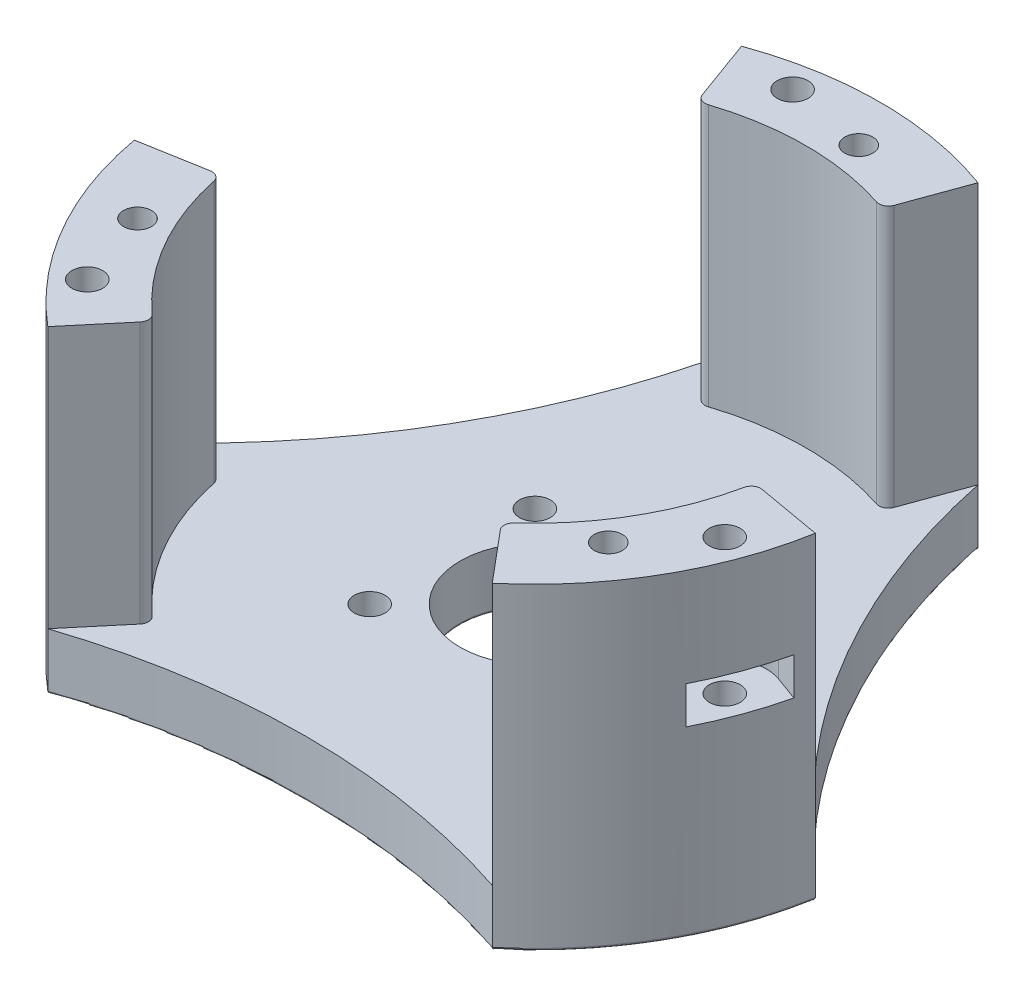
from build123d import *

# Parameters (mm, degrees)
SKETCH1_R           = 37
SKETCH1_R_2         = 1.65
BOSS_EXTRUDE1_DEPTH = 6
SKETCH2_R           = 1.5
BOSS_EXTRUDE2_DEPTH = 28
SKETCH16_R          = 1.5
CUT_EXTRUDE9_DEPTH  = 35
CIRPATTERN1_COUNT   = 3
SKETCH3_R           = 8
CUT_EXTRUDE1_DEPTH  = 10
SKETCH4_R           = 3.5
CUT_EXTRUDE2_DEPTH  = 3
SKETCH5_R           = 75.500139874
CUT_EXTRUDE3_DEPTH  = 7
CIRPATTERN2_COUNT   = 3
FILLET1_R           = 0.25
FILLET2_R           = 1
CUT_EXTRUDE4_START  = -24.5000001
SKETCH9_R           = 1.65
CUT_EXTRUDE4_DEPTH  = 36.0000001
CUT_EXTRUDE5_DEPTH  = 4
CIRPATTERN3_COUNT   = 3


with BuildPart() as part:
    # Sketch1 → Boss-Extrude1 (new body)
    with BuildSketch(Plane(origin=(0, 0, 0), x_dir=(1, 0, 0), z_dir=(0, 1, 0))):
        Circle(SKETCH1_R)
        with Locations((-8.838834765, 8.838834765)):
            Circle(SKETCH1_R_2, mode=Mode.SUBTRACT)
        with Locations((8.838834765, 8.838834765)):
            Circle(SKETCH1_R_2, mode=Mode.SUBTRACT)
        with Locations((8.838834765, -8.838834765)):
            Circle(SKETCH1_R_2, mode=Mode.SUBTRACT)
        with Locations((-8.838834765, -8.838834765)):
            Circle(SKETCH1_R_2, mode=Mode.SUBTRACT)
    extrude(amount=BOSS_EXTRUDE1_DEPTH)

    # Sketch2 → Boss-Extrude2 (add)
    with BuildSketch(Plane(origin=(0, 6, 0), x_dir=(1, 0, 0), z_dir=(0, 1, 0))):
        with BuildLine():
            Line((-12.654745303, 34.768626969), (-9.918584156, 27.251086003))
            ThreePointArc((-9.918584156, 27.251086003), (0, 29), (9.918584156, 27.251086003))
            Line((9.918584156, 27.251086003), (12.654745303, 34.768626969))
            ThreePointArc((12.654745303, 34.768626969), (0, 37), (-12.654745303, 34.768626969))
        make_face()
        with Locations((2.788983768, 31.878230339)):
            Circle(SKETCH2_R, mode=Mode.SUBTRACT)
    boss_extrude2 = extrude(amount=BOSS_EXTRUDE2_DEPTH)

    # Sketch16 → Cut-Extrude9 (cut, through all)
    with BuildSketch(Plane(origin=(0, 34, 0), x_dir=(1, 0, 0), z_dir=(0, 1, 0))):
        with Locations((2.788983768, 31.878230339)):
            Circle(SKETCH16_R)
    cut_extrude9 = extrude(amount=-CUT_EXTRUDE9_DEPTH, mode=Mode.SUBTRACT)

    # CirPattern1: Boss-Extrude2, Cut-Extrude9 ×3 about axis
    cirpattern1_axis = Axis((0, 0, 0), (0, 1, 0))
    for i in range(1, CIRPATTERN1_COUNT):
        add(boss_extrude2.rotate(cirpattern1_axis, i * 360 / CIRPATTERN1_COUNT))
        add(cut_extrude9.rotate(cirpattern1_axis, i * 360 / CIRPATTERN1_COUNT), mode=Mode.SUBTRACT)

    # Sketch3 → Cut-Extrude1 (cut)
    with BuildSketch(Plane(origin=(0, 6, 0), x_dir=(1, 0, 0), z_dir=(0, 1, 0))):
        Circle(SKETCH3_R)
    extrude(amount=-CUT_EXTRUDE1_DEPTH, mode=Mode.SUBTRACT)

    # Sketch4 → Cut-Extrude2 (cut)
    with BuildSketch(Plane.XZ):
        with Locations((8.838834765, 8.838834765)):
            Circle(SKETCH4_R)
        with Locations((8.838834765, -8.838834765)):
            Circle(SKETCH4_R)
        with Locations((-8.838834765, -8.838834765)):
            Circle(SKETCH4_R)
        with Locations((-8.838834765, 8.838834765)):
            Circle(SKETCH4_R)
    extrude(amount=-CUT_EXTRUDE2_DEPTH, mode=Mode.SUBTRACT)

    # Sketch5 → Cut-Extrude3 (cut, through all)
    with BuildSketch(Plane(origin=(0, 6, 0), x_dir=(1, 0, 0), z_dir=(0, 1, 0))):
        with Locations((86.602540378, 50)):
            Circle(SKETCH5_R)
    cut_extrude3 = extrude(amount=-CUT_EXTRUDE3_DEPTH, mode=Mode.SUBTRACT)

    # CirPattern2: Cut-Extrude3 ×3 about axis
    cirpattern2_axis = Axis((0, 0, 0), (0, 1, 0))
    for i in range(1, CIRPATTERN2_COUNT):
        add(cut_extrude3.rotate(cirpattern2_axis, i * 360 / CIRPATTERN2_COUNT), mode=Mode.SUBTRACT)

    # Fillet1
    fillet1_edges = [part.edges().sort_by_distance(p)[0] for p in [
        (-12.338834765, 0, -8.838834765),
        (5.338834765, 0, -8.838834765),
        (5.338834765, 0, 8.838834765),
        (0, 0, -37),
        (21.217501259, 0, -12.249930063),
        (-32.04293994, 0, 18.5),
        (32.04293994, 0, 18.5),
        (0, 0, 24.499860126),
        (-21.217501259, 0, -12.249930063),
        (1.288983768, 0, -31.878230339),
        (-28.251849185, 0, 14.822822481),
        (26.962865417, 0, 17.055407858),
        (-8, 0, 0),
        (-12.338834765, 0, 8.838834765),
    ]]
    fillet(fillet1_edges, radius=FILLET1_R)

    # Fillet2
    fillet2_edges = [part.edges().sort_by_distance(p)[0] for p in [
        (-9.918584156, 20, -27.251086003),
        (9.918584156, 20, -27.251086003),
        (-18.640840681, 20, 22.21528885),
        (-28.559424837, 20, 5.035797152),
        (28.559424837, 20, 5.035797152),
        (18.640840681, 20, 22.21528885),
    ]]
    fillet(fillet2_edges, radius=FILLET2_R)

    # Sketch9 → Cut-Extrude4 (cut)
    with BuildSketch(Plane(origin=(0, 23.5, 0), x_dir=(1, 0, 0), z_dir=(0, 1, 0)).offset(CUT_EXTRUDE4_START)):
        with Locations((-5.904038041, 33.483463602)):
            Circle(SKETCH9_R)
    cut_extrude4 = extrude(amount=CUT_EXTRUDE4_DEPTH, mode=Mode.SUBTRACT)

    # Sketch10 → Cut-Extrude5 (cut)
    with BuildSketch(Plane(origin=(0, 23.5, 0), x_dir=(1, 0, 0), z_dir=(0, 1, 0))):
        with BuildLine():
            Line((-11.203913818, 37.626085568), (-10.335672929, 32.702046803))
            ThreePointArc((-10.335672929, 32.702046803), (-5.122621241, 29.051828714), (-1.472403152, 34.264880402))
            Line((-1.472403152, 34.264880402), (-2.34064404, 39.188919167))
            Line((-2.34064404, 39.188919167), (-11.203913818, 37.626085568))
        make_face()
    cut_extrude5 = extrude(amount=-CUT_EXTRUDE5_DEPTH, mode=Mode.SUBTRACT)

    # CirPattern3: Cut-Extrude4, Cut-Extrude5 ×3 about axis
    cirpattern3_axis = Axis((0, 0, 0), (0, 1, 0))
    for i in range(1, CIRPATTERN3_COUNT):
        add(cut_extrude4.rotate(cirpattern3_axis, i * 360 / CIRPATTERN3_COUNT), mode=Mode.SUBTRACT)
        add(cut_extrude5.rotate(cirpattern3_axis, i * 360 / CIRPATTERN3_COUNT), mode=Mode.SUBTRACT)


solid = part.part
